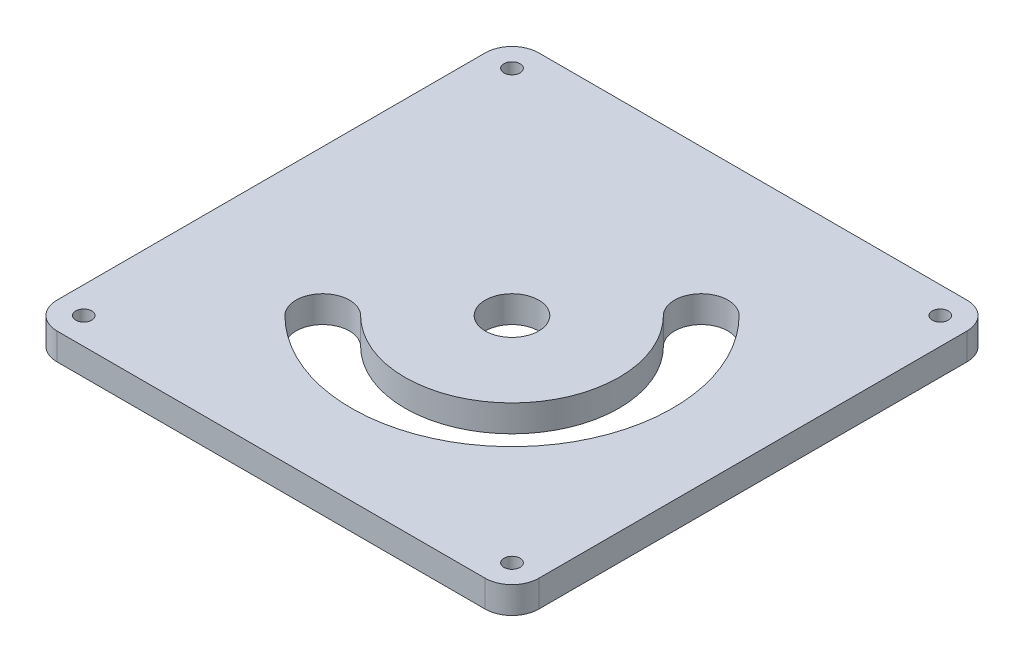
from build123d import *

# Parameters (mm, degrees)
SKETCH1_W           = 90
SKETCH1_H           = 90
SKETCH1_R           = 5
BOSS_EXTRUDE1_DEPTH = 5
SKETCH2_R           = 1.5
CUT_EXTRUDE1_DEPTH  = 6
FILLET1_R           = 5


with BuildPart() as part:
    # Sketch1 → Boss-Extrude1 (new body)
    with BuildSketch(Plane(origin=(0, 0, 0), x_dir=(1, 0, 0), z_dir=(0, 1, 0))):
        Rectangle(SKETCH1_W, SKETCH1_H)
        Circle(SKETCH1_R, mode=Mode.SUBTRACT)
        with BuildLine():
            ThreePointArc((-21.213203436, -21.213203436), (21.213203436, -21.213203436), (21.213203436, 21.213203436))
            ThreePointArc((21.213203436, 21.213203436), (14.142135624, 21.213203436), (14.142135624, 14.142135624))
            ThreePointArc((14.142135624, 14.142135624), (14.142135624, -14.142135624), (-14.142135624, -14.142135624))
            ThreePointArc((-14.142135624, -14.142135624), (-21.213203436, -14.142135624), (-21.213203436, -21.213203436))
        make_face(mode=Mode.SUBTRACT)
    extrude(amount=BOSS_EXTRUDE1_DEPTH)

    # Sketch2 → Cut-Extrude1 (cut, through all)
    with BuildSketch(Plane(origin=(0, 5, 0), x_dir=(1, 0, 0), z_dir=(0, 1, 0))):
        with Locations((-40, 40)):
            Circle(SKETCH2_R)
        with Locations((40, 40)):
            Circle(SKETCH2_R)
        with Locations((40, -40)):
            Circle(SKETCH2_R)
        with Locations((-40, -40)):
            Circle(SKETCH2_R)
    extrude(amount=-CUT_EXTRUDE1_DEPTH, mode=Mode.SUBTRACT)

    # Fillet1
    fillet1_edges = [part.edges().sort_by_distance(p)[0] for p in [
        (45, 2.5, 45),
        (-45, 2.5, 45),
        (-45, 2.5, -45),
        (45, 2.5, -45),
    ]]
    fillet(fillet1_edges, radius=FILLET1_R)


solid = part.part
